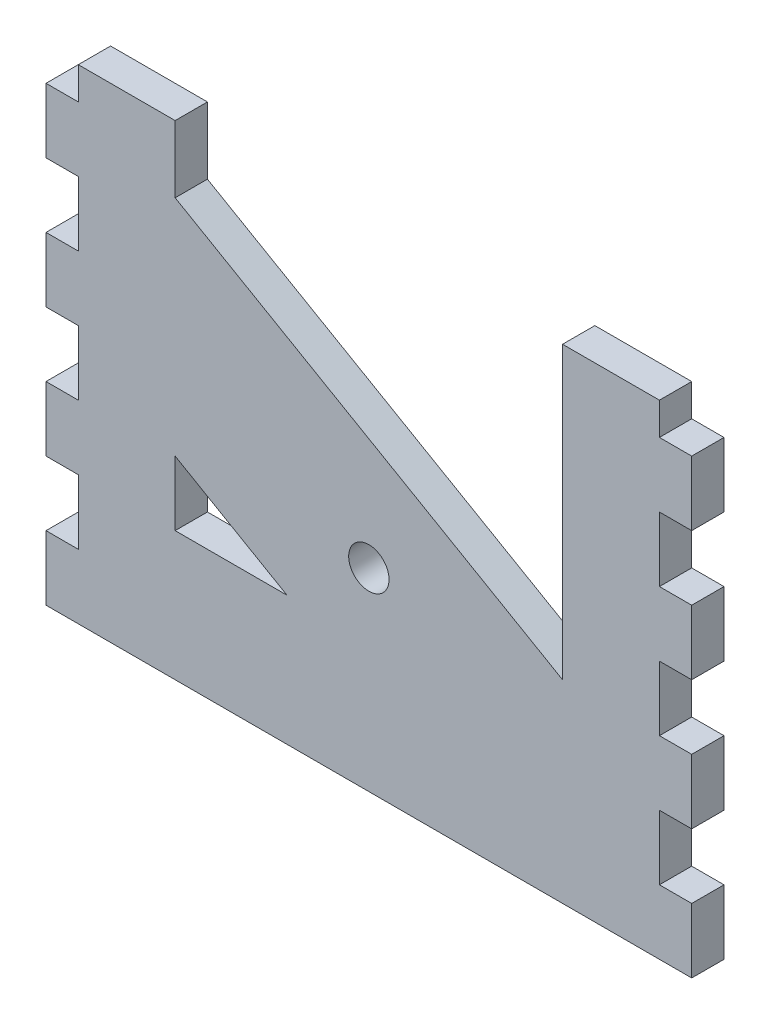
from build123d import *

# Parameters (mm, degrees)
SKETCH1_W           = 127
SKETCH1_H           = 95.25
BOSS_EXTRUDE1_DEPTH = 6.35
SKETCH2_R           = 3.96875
CUT_EXTRUDE1_DEPTH  = 7.35
SKETCH3_W           = 6.35
SKETCH3_H           = 12.7
CUT_EXTRUDE2_DEPTH  = 7.35
SKETCH4_W           = 6.35
SKETCH4_H           = 12.7
CUT_EXTRUDE3_DEPTH  = 7.35
LPATTERN1_COUNT     = 4
LPATTERN1_PITCH     = 25.4
CUT_EXTRUDE4_DEPTH  = 7.35


with BuildPart() as part:
    # Sketch1 → Boss-Extrude1 (new body)
    with BuildSketch(Plane.XY):
        with Locations((63.5, 47.625)):
            Rectangle(SKETCH1_W, SKETCH1_H)
    extrude(amount=BOSS_EXTRUDE1_DEPTH)

    # Sketch2 → Cut-Extrude1 (cut, through all)
    with BuildSketch(Plane.XY.offset(6.35)):
        with Locations((63.5, 38.1)):
            Circle(SKETCH2_R)
    extrude(amount=-CUT_EXTRUDE1_DEPTH, mode=Mode.SUBTRACT)

    # Sketch3 → Cut-Extrude2 (cut, through all)
    with BuildSketch(Plane.XY.offset(6.35)):
        with Locations((3.175, 19.05)):
            Rectangle(SKETCH3_W, SKETCH3_H)
    cut_extrude2 = extrude(amount=-CUT_EXTRUDE2_DEPTH, mode=Mode.SUBTRACT)

    # Sketch4 → Cut-Extrude3 (cut, through all)
    with BuildSketch(Plane.XY.offset(6.35)):
        with Locations((123.825, 19.05)):
            Rectangle(SKETCH4_W, SKETCH4_H)
    cut_extrude3 = extrude(amount=-CUT_EXTRUDE3_DEPTH, mode=Mode.SUBTRACT)

    # LPattern1: Cut-Extrude2, Cut-Extrude3 ×4
    with Locations(*[(0, i * LPATTERN1_PITCH, 0) for i in range(1, LPATTERN1_COUNT)]):
        add(cut_extrude2, mode=Mode.SUBTRACT)
        add(cut_extrude3, mode=Mode.SUBTRACT)

    # Sketch5 → Cut-Extrude4 (cut, through all)
    with BuildSketch(Plane.XY.offset(6.35)):
        Polygon((25.4, 95.25), (25.4, 82.094090512), (101.6, 38.1), (101.6, 95.25), align=None)
        Polygon((25.4, 38.1), (47.397045256, 25.4), (25.4, 25.4), align=None)
    extrude(amount=-CUT_EXTRUDE4_DEPTH, mode=Mode.SUBTRACT)


solid = part.part
